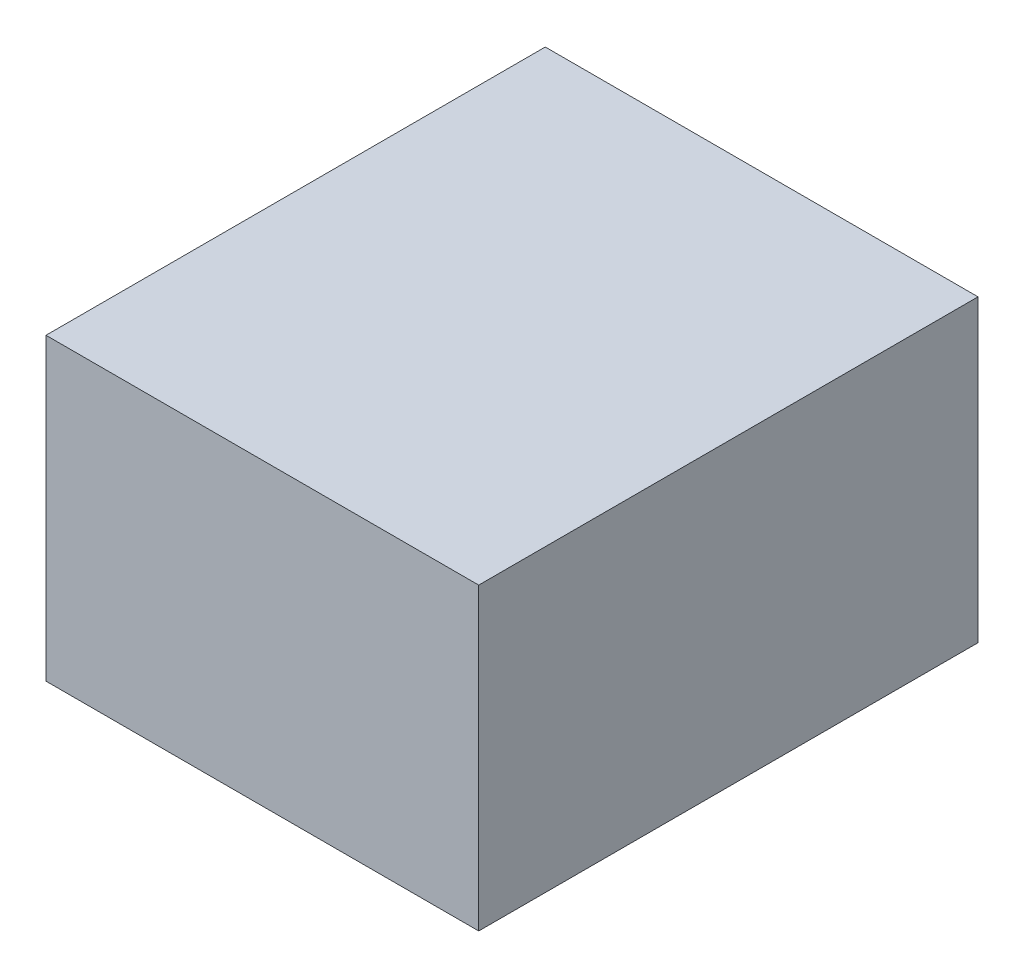
from build123d import *

# Parameters (mm, degrees)
SKETCH1_W           = 330.2
SKETCH1_H           = 228.6
BOSS_EXTRUDE1_DEPTH = 381


with BuildPart() as part:
    # Sketch1 → Boss-Extrude1 (new body)
    with BuildSketch(Plane.XY):
        with Locations((165.1, 114.3)):
            Rectangle(SKETCH1_W, SKETCH1_H)
    extrude(amount=BOSS_EXTRUDE1_DEPTH)


solid = part.part
